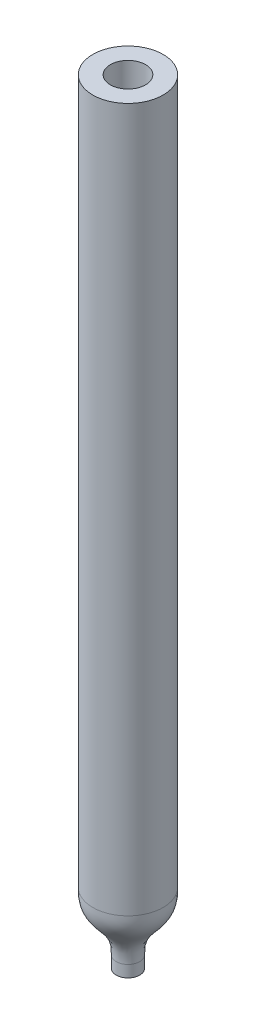
from build123d import *


with BuildPart() as part:
    # Sketch1 → Revolve1 (revolve)
    with BuildSketch(Plane.XY):
        with BuildLine():
            Line((1.5, 61), (3, 61))
            Line((3, 61), (3, 1))
            add(Edge.make_bspline(
                [(1, -4), (1, -2.852326224), (1, -1.704652447), (3, -1.295347553), (3, -0.147673776), (3, 1)],
                knots=[0, 0, 0, 0, 0, 0, 1, 1, 1, 1, 1, 1], degree=5))
            Line((1, -4), (1, -5))
            Line((1, -5), (0.25, -5))
            Line((0.25, -5), (0.25, -4))
            add(Edge.make_bspline(
                [(0.25, -4), (0.25, -2.870146948), (0.25, -1.740293897), (1.5, -2.259706103), (1.5, -1.129853052), (1.5, 0)],
                knots=[0, 0, 0, 0, 0, 0, 1, 1, 1, 1, 1, 1], degree=5))
            Line((1.5, 0), (1.5, 61))
        make_face()
    revolve(axis=Axis((0, 0, 0), (0, -1, 0)))


solid = part.part
